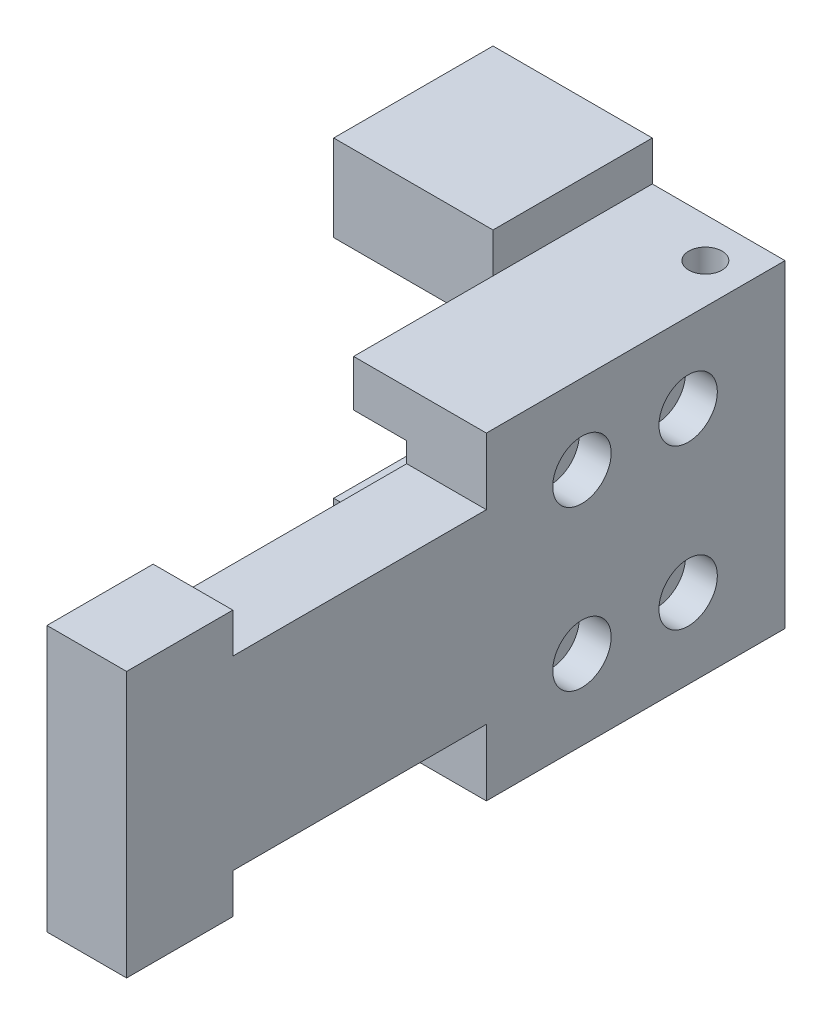
from build123d import *

# Parameters (mm, degrees)
EXTRUDE_1_DEPTH              = 49.6
CUT_EXTRUDE_1_DEPTH          = 31
CUT_EXTRUDE_2_DEPTH          = 49.6
HOLE_WIZARD_M2_1_D           = 2.4
HOLE_WIZARD_M2_1_DEPTH       = 10.1
HOLE_WIZARD_M2_1_CBORE_D     = 4.4
HOLE_WIZARD_M2_1_CBORE_DEPTH = 2.4
HOLE_WIZARD_M2_1_TIP         = 0.721032743
SKETCH_6_R                   = 2.55
CUT_EXTRUDE_3_DEPTH          = 6
HOLE_WIZARD_M3_1_D           = 2.5
HOLE_WIZARD_M3_1_DEPTH       = 7.5
HOLE_WIZARD_M3_1_TIP         = 0.751075774


with BuildPart() as part:
    # 草图1 → 凸台-拉伸1 (new body)
    with BuildSketch(Plane.XY):
        Polygon((-6, 8.5), (-6, -8.5), (-10, -8.5), (-22, -8.5), (-22, -15), (-10, -15), (-10, -12), (0, -12), (0, -10), (0, 10), (0, 12), (-10, 12), (-10, 15), (-22, 15), (-22, 8.5), (-10, 8.5), align=None)
    extrude(amount=EXTRUDE_1_DEPTH)

    # 草图2 → 切除-拉伸1 (cut, through all)
    with BuildSketch(Plane.XZ.offset(15)):
        Polygon((-22, 49.6), (-12.955077182, 49.6), (-6, 49.6), (-6, 22.5), (-10, 22.5), (-10, 12), (-22, 12), align=None)
    extrude(amount=-CUT_EXTRUDE_1_DEPTH, mode=Mode.SUBTRACT)

    # 草图3 → 切除-拉伸2 (cut)
    with BuildSketch(Plane(origin=(0, 0, 0), x_dir=(0, 0, -1), z_dir=(1, 0, 0))):
        Polygon((-22.5, 12), (-41.6, 12), (-49.6, 12), (-49.6, 10), (-41.6, 10), (-41.6, 7), (-22.5, 7), align=None)
        Polygon((-41.6, -12), (-49.6, -12), (-49.6, -10), (-41.6, -10), (-41.6, -7), (-22.5, -7), (-22.5, -12), align=None)
    extrude(amount=-CUT_EXTRUDE_2_DEPTH, mode=Mode.SUBTRACT)

    # M2 六角凹头螺钉的柱形沉头孔1
    with Locations(Plane(origin=(0, 0, 0), x_dir=(0, 0, -1), z_dir=(1, 0, 0))):
        with Locations((-15.3, 6), (-7.3, 6), (-15.3, -6), (-7.3, -6)):
            CounterBoreHole(HOLE_WIZARD_M2_1_D / 2, HOLE_WIZARD_M2_1_CBORE_D / 2, HOLE_WIZARD_M2_1_CBORE_DEPTH, depth=HOLE_WIZARD_M2_1_DEPTH)
            with Locations((0, 0, -(HOLE_WIZARD_M2_1_DEPTH + HOLE_WIZARD_M2_1_TIP / 2))):  # 118° drill point
                Cone(0, HOLE_WIZARD_M2_1_D / 2, HOLE_WIZARD_M2_1_TIP, mode=Mode.SUBTRACT)

    # 草图6 → 切除-拉伸3 (cut)
    with BuildSketch(Plane(origin=(0, 0, 0), x_dir=(-1, 0, 0), z_dir=(0, 0, -1))):
        with Locations((17, -11.75)):
            Circle(SKETCH_6_R)
        with Locations((17, 11.75)):
            Circle(SKETCH_6_R)
    extrude(amount=-CUT_EXTRUDE_3_DEPTH, mode=Mode.SUBTRACT)

    # M3 螺纹孔1
    with Locations(Plane(origin=(0, 12, 0), x_dir=(1, 0, 0), z_dir=(0, 1, 0))):
        with Locations((-3, -3)):
            Hole(HOLE_WIZARD_M3_1_D / 2, depth=HOLE_WIZARD_M3_1_DEPTH)
            with Locations((0, 0, -(HOLE_WIZARD_M3_1_DEPTH + HOLE_WIZARD_M3_1_TIP / 2))):  # 118° drill point
                Cone(0, HOLE_WIZARD_M3_1_D / 2, HOLE_WIZARD_M3_1_TIP, mode=Mode.SUBTRACT)


solid = part.part
